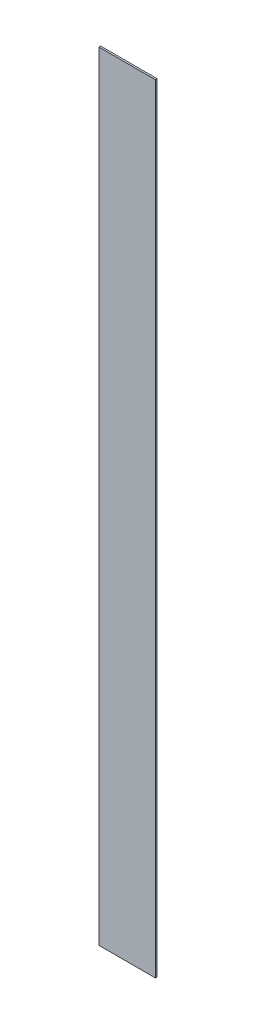
from build123d import *

# Parameters (mm, degrees)
SKETCH1_W           = 25.4
SKETCH1_H           = 349.25
BOSS_EXTRUDE1_DEPTH = 0.396875


with BuildPart() as part:
    # Sketch1 → Boss-Extrude1 (new body, symmetric)
    with BuildSketch(Plane.XY):
        Rectangle(SKETCH1_W, SKETCH1_H)
    extrude(amount=BOSS_EXTRUDE1_DEPTH, both=True)


solid = part.part
